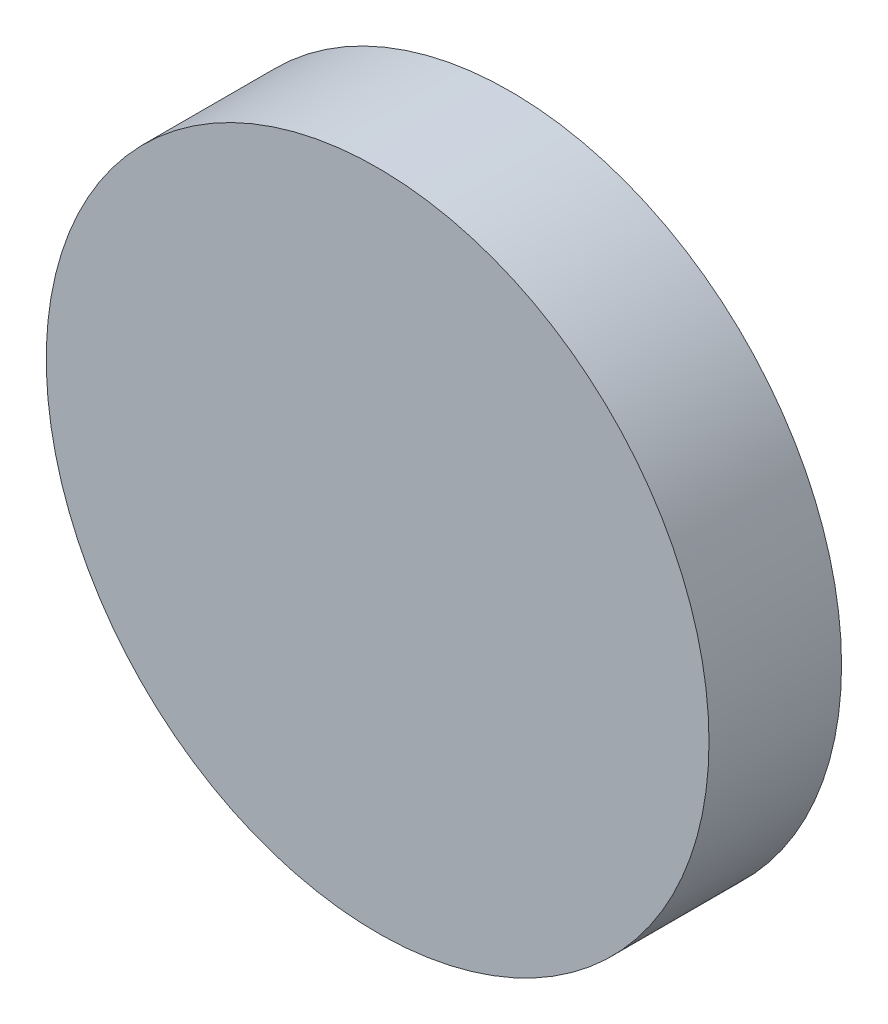
from build123d import *

# Parameters (mm, degrees)
SKETCH_1_R      = 15
EXTRUDE_1_DEPTH = 6


with BuildPart() as part:
    # 草图1 → 凸台-拉伸1 (new body)
    with BuildSketch(Plane.XY):
        Circle(SKETCH_1_R)
    extrude(amount=EXTRUDE_1_DEPTH)


solid = part.part
